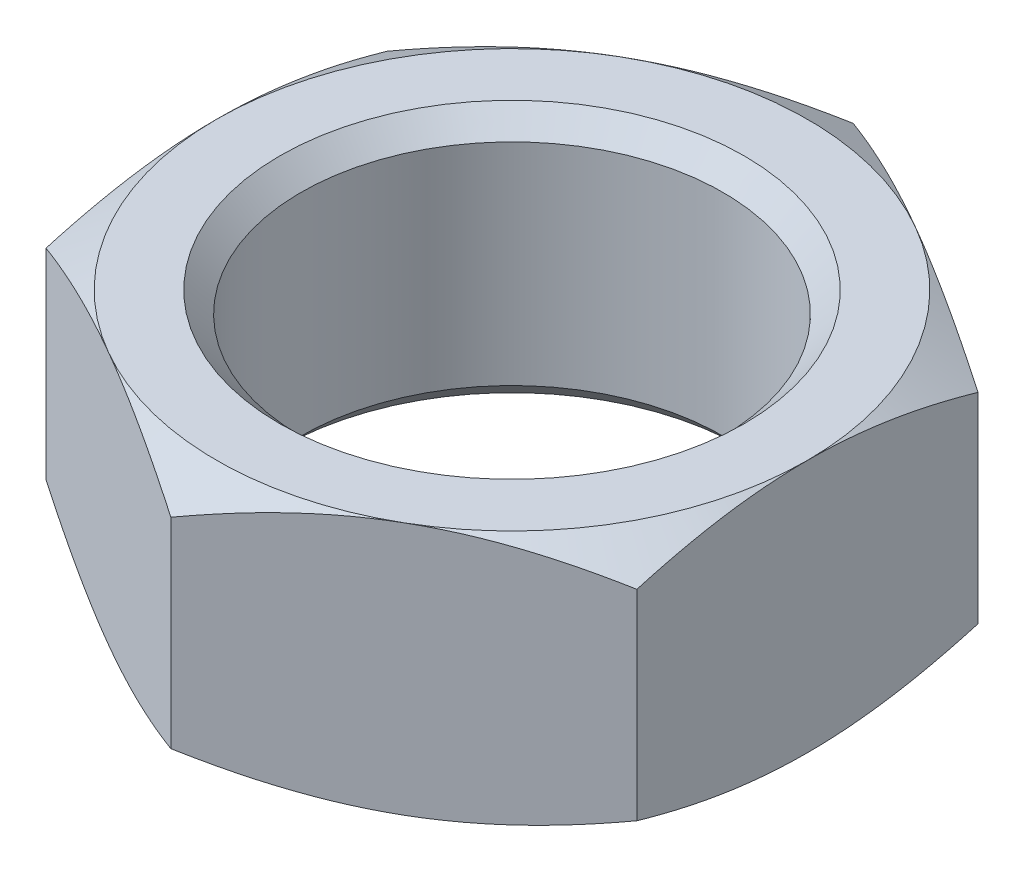
from build123d import *

# Parameters (mm, degrees)
BOSS_EXTRUDE1_DEPTH = 6
SKETCH2_OUTSIDE_W   = 80.454
SKETCH2_OUTSIDE_H   = 84.786
SKETCH2_OUTSIDE_R   = 14
CUT_EXTRUDE1_DEPTH  = 12
CUT_EXTRUDE1_TAPER  = 60
SKETCH3_R           = 10
CUT_EXTRUDE2_DEPTH  = 13
CHAMFER1_SIZE       = 1


with BuildPart() as part:
    # Sketch1 → Boss-Extrude1 (new body, symmetric)
    with BuildSketch(Plane(origin=(0, 0, 0), x_dir=(1, 0, 0), z_dir=(0, 1, 0))):
        Polygon((14, 8.082903769), (0, 16.165807537), (-14, 8.082903769), (-14, -8.082903769), (0, -16.165807537), (14, -8.082903769), align=None)
    extrude(amount=BOSS_EXTRUDE1_DEPTH, both=True)

    # Sketch2 outside → Cut-Extrude1 (cut)
    with BuildSketch(Plane(origin=(0, 6, 0), x_dir=(1, 0, 0), z_dir=(0, 1, 0))):
        Rectangle(SKETCH2_OUTSIDE_W, SKETCH2_OUTSIDE_H)
        Circle(SKETCH2_OUTSIDE_R, mode=Mode.SUBTRACT)
    cut_extrude1 = extrude(amount=-CUT_EXTRUDE1_DEPTH, taper=CUT_EXTRUDE1_TAPER, mode=Mode.SUBTRACT)

    # Mirror1: Cut-Extrude1 across plane
    add(cut_extrude1.mirror(Plane.ZX), mode=Mode.SUBTRACT)

    # Sketch3 → Cut-Extrude2 (cut, through all)
    with BuildSketch(Plane(origin=(0, 6, 0), x_dir=(1, 0, 0), z_dir=(0, 1, 0))):
        Circle(SKETCH3_R)
    extrude(amount=-CUT_EXTRUDE2_DEPTH, mode=Mode.SUBTRACT)

    # Chamfer1
    chamfer1_edges = [part.edges().sort_by_distance(p)[0] for p in [
        (-10, -6, 0),
        (-10, 6, 0),
    ]]
    chamfer(chamfer1_edges, length=CHAMFER1_SIZE)


solid = part.part
